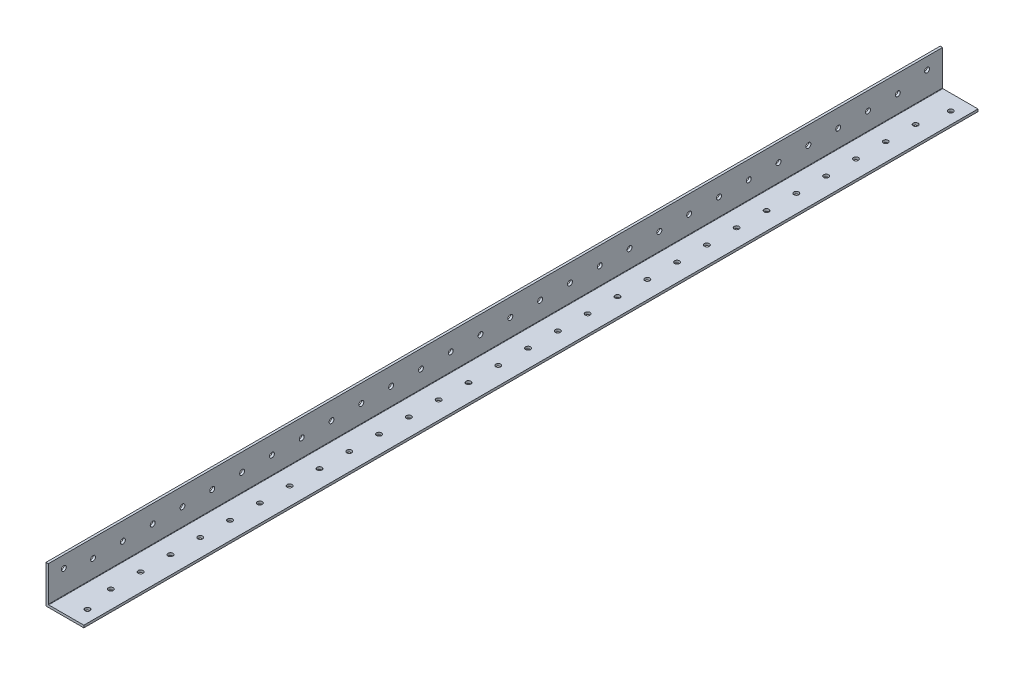
from build123d import *

# Parameters (mm, degrees)
BOSS_EXTRUDE1_DEPTH = 1219.2
FILLET1_R           = 0.254
SKETCH4_W           = 1838.4
SKETCH4_H           = 74.945320812
CUT_EXTRUDE1_DEPTH  = 60
SKETCH5_R           = 1.65
CUT_EXTRUDE2_DEPTH  = 60
SKETCH6_R           = 1.65
CUT_EXTRUDE3_DEPTH  = 60


with BuildPart() as part:
    # Sketch3 → Boss-Extrude1 (new, symmetric)
    with BuildSketch(Plane.XY):
        Polygon((1.5875, 25.4), (0, 25.4), (0, 0), (25.4, 0), (25.4, 1.5875), (1.5875, 1.5875), align=None)
    extrude(amount=BOSS_EXTRUDE1_DEPTH, both=True)

    # Fillet1
    fillet1_edges = [part.edges().sort_by_distance(p)[0] for p in [
        (1.5875, 1.5875, 0),
    ]]
    fillet(fillet1_edges, radius=FILLET1_R)

    # Sketch4 → Cut-Extrude1 (cut)
    with BuildSketch(Plane.ZY):
        with Locations((-300, 37.472660406)):
            Rectangle(SKETCH4_W, SKETCH4_H)
    extrude(amount=-CUT_EXTRUDE1_DEPTH, mode=Mode.SUBTRACT)

    # Sketch5 → Cut-Extrude2 (cut)
    with BuildSketch(Plane(origin=(1.5875, 0, 0), x_dir=(0, 0, -1), z_dir=(1, 0, 0))):
        with Locations((-629.5759, 17.4625)):
            Circle(SKETCH5_R)
        with Locations((-1208.8241, 17.4625)):
            Circle(SKETCH5_R)
        with Locations((-1189.2, 13.49375)):
            Circle(SKETCH5_R)
        with Locations((-1169.2, 13.49375)):
            Circle(SKETCH5_R)
        with Locations((-1149.2, 13.49375)):
            Circle(SKETCH5_R)
        with Locations((-1129.2, 13.49375)):
            Circle(SKETCH5_R)
        with Locations((-1109.2, 13.49375)):
            Circle(SKETCH5_R)
        with Locations((-1089.2, 13.49375)):
            Circle(SKETCH5_R)
        with Locations((-1069.2, 13.49375)):
            Circle(SKETCH5_R)
        with Locations((-1049.2, 13.49375)):
            Circle(SKETCH5_R)
        with Locations((-1029.2, 13.49375)):
            Circle(SKETCH5_R)
        with Locations((-1009.2, 13.49375)):
            Circle(SKETCH5_R)
        with Locations((-989.2, 13.49375)):
            Circle(SKETCH5_R)
        with Locations((-969.2, 13.49375)):
            Circle(SKETCH5_R)
        with Locations((-949.2, 13.49375)):
            Circle(SKETCH5_R)
        with Locations((-929.2, 13.49375)):
            Circle(SKETCH5_R)
        with Locations((-909.2, 13.49375)):
            Circle(SKETCH5_R)
        with Locations((-889.2, 13.49375)):
            Circle(SKETCH5_R)
        with Locations((-869.2, 13.49375)):
            Circle(SKETCH5_R)
        with Locations((-849.2, 13.49375)):
            Circle(SKETCH5_R)
        with Locations((-829.2, 13.49375)):
            Circle(SKETCH5_R)
        with Locations((-809.2, 13.49375)):
            Circle(SKETCH5_R)
        with Locations((-789.2, 13.49375)):
            Circle(SKETCH5_R)
        with Locations((-769.2, 13.49375)):
            Circle(SKETCH5_R)
        with Locations((-749.2, 13.49375)):
            Circle(SKETCH5_R)
        with Locations((-729.2, 13.49375)):
            Circle(SKETCH5_R)
        with Locations((-709.2, 13.49375)):
            Circle(SKETCH5_R)
        with Locations((-689.2, 13.49375)):
            Circle(SKETCH5_R)
        with Locations((-669.2, 13.49375)):
            Circle(SKETCH5_R)
        with Locations((-649.2, 13.49375)):
            Circle(SKETCH5_R)
    extrude(amount=-CUT_EXTRUDE2_DEPTH, mode=Mode.SUBTRACT)

    # Sketch6 → Cut-Extrude3 (cut)
    with BuildSketch(Plane(origin=(0, 1.5875, 0), x_dir=(1, 0, 0), z_dir=(0, 1, 0))):
        with Locations(Location((17.4625, -629.5759, 0), (0, 0, 180))):
            Circle(SKETCH6_R)
        with Locations(Location((17.4625, -1208.8241, 0), (0, 0, 180))):
            Circle(SKETCH6_R)
        with Locations(Location((13.49375, -649.2, 0), (0, 0, 180))):
            Circle(SKETCH6_R)
        with Locations(Location((13.49375, -669.2, 0), (0, 0, 180))):
            Circle(SKETCH6_R)
        with Locations(Location((13.49375, -689.2, 0), (0, 0, 180))):
            Circle(SKETCH6_R)
        with Locations(Location((13.49375, -709.2, 0), (0, 0, 180))):
            Circle(SKETCH6_R)
        with Locations(Location((13.49375, -729.2, 0), (0, 0, 180))):
            Circle(SKETCH6_R)
        with Locations(Location((13.49375, -749.2, 0), (0, 0, 180))):
            Circle(SKETCH6_R)
        with Locations(Location((13.49375, -769.2, 0), (0, 0, 180))):
            Circle(SKETCH6_R)
        with Locations(Location((13.49375, -789.2, 0), (0, 0, 180))):
            Circle(SKETCH6_R)
        with Locations(Location((13.49375, -809.2, 0), (0, 0, 180))):
            Circle(SKETCH6_R)
        with Locations(Location((13.49375, -829.2, 0), (0, 0, 180))):
            Circle(SKETCH6_R)
        with Locations(Location((13.49375, -849.2, 0), (0, 0, 180))):
            Circle(SKETCH6_R)
        with Locations(Location((13.49375, -869.2, 0), (0, 0, 180))):
            Circle(SKETCH6_R)
        with Locations(Location((13.49375, -889.2, 0), (0, 0, 180))):
            Circle(SKETCH6_R)
        with Locations(Location((13.49375, -909.2, 0), (0, 0, 180))):
            Circle(SKETCH6_R)
        with Locations(Location((13.49375, -929.2, 0), (0, 0, 180))):
            Circle(SKETCH6_R)
        with Locations(Location((13.49375, -949.2, 0), (0, 0, 180))):
            Circle(SKETCH6_R)
        with Locations(Location((13.49375, -969.2, 0), (0, 0, 180))):
            Circle(SKETCH6_R)
        with Locations(Location((13.49375, -989.2, 0), (0, 0, 180))):
            Circle(SKETCH6_R)
        with Locations(Location((13.49375, -1009.2, 0), (0, 0, 180))):
            Circle(SKETCH6_R)
        with Locations(Location((13.49375, -1029.2, 0), (0, 0, 180))):
            Circle(SKETCH6_R)
        with Locations(Location((13.49375, -1049.2, 0), (0, 0, 180))):
            Circle(SKETCH6_R)
        with Locations(Location((13.49375, -1069.2, 0), (0, 0, 180))):
            Circle(SKETCH6_R)
        with Locations(Location((13.49375, -1089.2, 0), (0, 0, 180))):
            Circle(SKETCH6_R)
        with Locations(Location((13.49375, -1109.2, 0), (0, 0, 180))):
            Circle(SKETCH6_R)
        with Locations(Location((13.49375, -1129.2, 0), (0, 0, 180))):
            Circle(SKETCH6_R)
        with Locations(Location((13.49375, -1149.2, 0), (0, 0, 180))):
            Circle(SKETCH6_R)
        with Locations(Location((13.49375, -1169.2, 0), (0, 0, 180))):
            Circle(SKETCH6_R)
        with Locations(Location((13.49375, -1189.2, 0), (0, 0, 180))):
            Circle(SKETCH6_R)
    extrude(amount=-CUT_EXTRUDE3_DEPTH, mode=Mode.SUBTRACT)


solid = part.part
